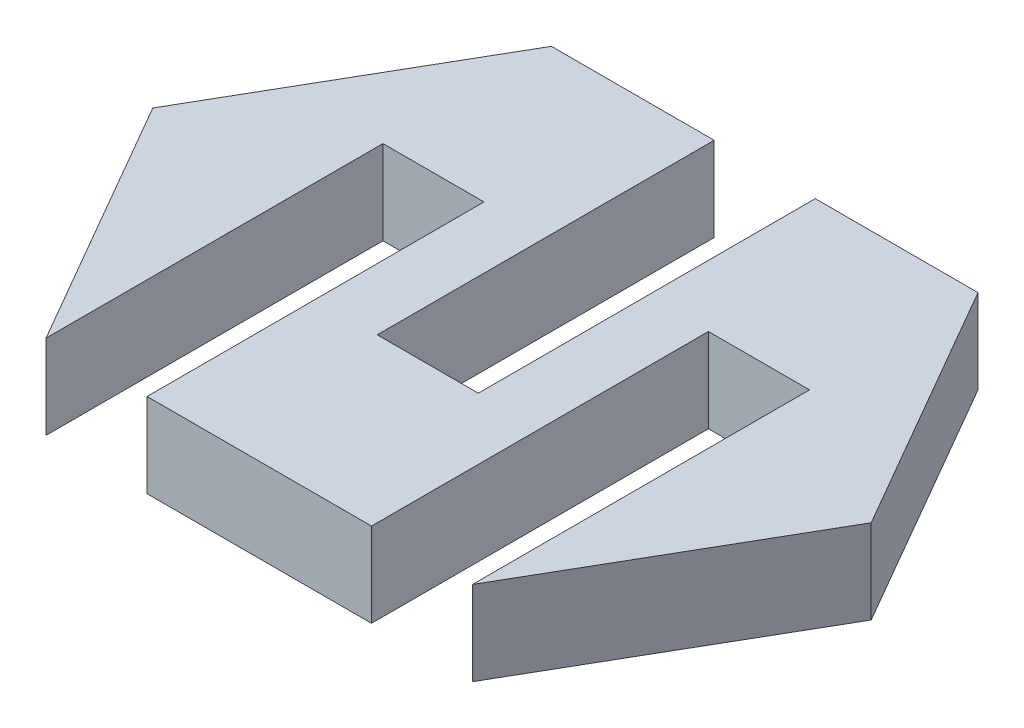
from build123d import *

# Parameters (mm, degrees)
BOSS_EXTRUDE1_DEPTH = 2.5
SKETCH5_W           = 3
SKETCH5_H           = 2.5
CUT_EXTRUDE2_DEPTH  = 10
SKETCH6_W           = 3
SKETCH6_H           = 2.5
CUT_EXTRUDE3_DEPTH  = 10
SKETCH7_W           = 3
SKETCH7_H           = 2.5
CUT_EXTRUDE4_DEPTH  = 10


with BuildPart() as part:
    # Sketch1 → Boss-Extrude1 (new body)
    with BuildSketch(Plane(origin=(0, 0, 0), x_dir=(1, 0, 0), z_dir=(0, 1, 0))):
        Polygon((8.581310361, -0.009375041), (4.251183342, 7.490624959), (-8.409070695, 7.490624959), (-12.739197714, -0.009375041), (-8.409070695, -7.509375041), (4.251183342, -7.509375041), align=None)
    extrude(amount=BOSS_EXTRUDE1_DEPTH)

    # Sketch5 → Cut-Extrude2 (cut)
    with BuildSketch(Plane.XY.offset(7.509375041)):
        with Locations((-6.909070695, 1.25)):
            Rectangle(SKETCH5_W, SKETCH5_H)
    extrude(amount=-CUT_EXTRUDE2_DEPTH, mode=Mode.SUBTRACT)

    # Sketch6 → Cut-Extrude3 (cut)
    with BuildSketch(Plane.XY.offset(7.509375041)):
        with Locations((2.751183342, 1.25)):
            Rectangle(SKETCH6_W, SKETCH6_H)
    extrude(amount=-CUT_EXTRUDE3_DEPTH, mode=Mode.SUBTRACT)

    # Sketch7 → Cut-Extrude4 (cut)
    with BuildSketch(Plane(origin=(0, 0, -7.490624959), x_dir=(-1, 0, 0), z_dir=(0, 0, -1))):
        with Locations((2.078816658, 1.25)):
            Rectangle(SKETCH7_W, SKETCH7_H)
    extrude(amount=-CUT_EXTRUDE4_DEPTH, mode=Mode.SUBTRACT)


solid = part.part
